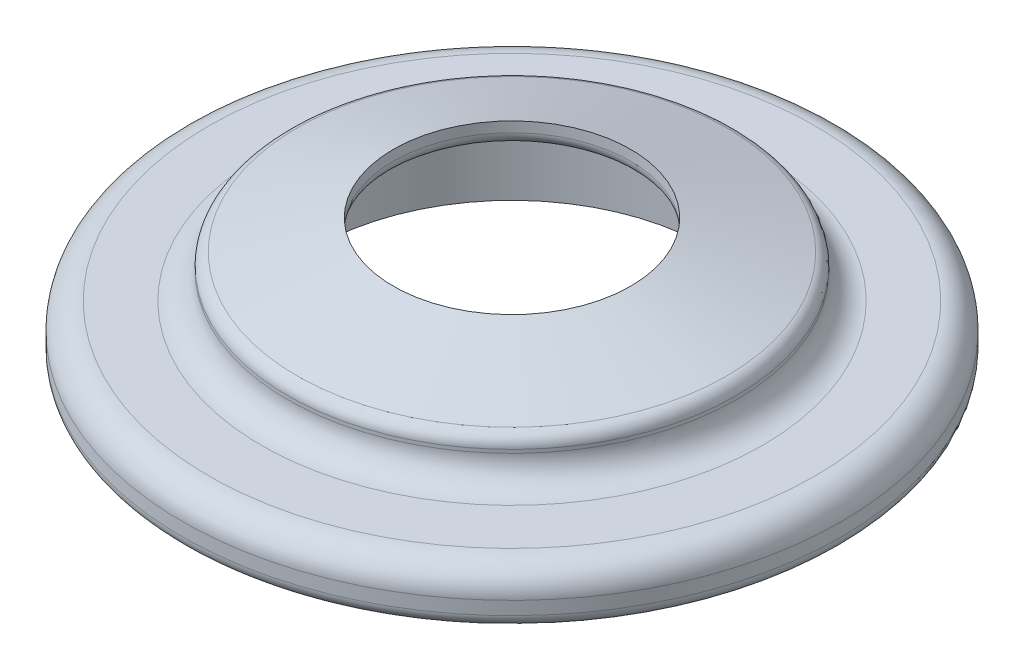
from build123d import *


with BuildPart() as part:
    # Sketch1 → Revolve1 (revolve)
    with BuildSketch(Plane.XY):
        with BuildLine():
            Line((0, 0), (-24, 0))
            ThreePointArc((-24, 0), (-24.707106781, 0.292893219), (-25, 1))
            Line((-25, 1), (-25, 2))
            ThreePointArc((-25, 2), (-24.414213562, 3.414213562), (-23, 4))
            Line((-23, 4), (-19, 4))
            ThreePointArc((-19, 4), (-17.585786438, 4.585786438), (-17, 6))
            Line((-17, 6), (-17, 6.261425345))
            ThreePointArc((-17, 6.261425345), (-16.804389784, 6.855527252), (-16.294085849, 7.217204354))
            Line((-16.294085849, 7.217204354), (-4.143718222, 10.955779009))
            ThreePointArc((-4.143718222, 10.955779009), (-3.998328357, 10.988882958), (-3.849632373, 11))
            Line((-3.849632373, 11), (0, 11))
            Line((0, 11), (0, 0))
        make_face()
    revolve(axis=Axis((0, 0, 0), (0, 1, 0)))

    # Sketch3 → Cut-Revolve2 (revolve, cut)
    with BuildSketch(Plane.XY):
        with BuildLine():
            Line((0, 11), (0, 0))
            Line((0, 0), (-15, 0))
            Line((-15, 0), (-15, 6.305273568))
            ThreePointArc((-15, 6.305273568), (-14.738894744, 6.979094433), (-14.091930885, 7.301038958))
            Line((-14.091930885, 7.301038958), (-9.908069115, 7.687300741))
            ThreePointArc((-9.908069115, 7.687300741), (-9.261105256, 8.009245267), (-9, 8.683066131))
            Line((-9, 8.683066131), (-9, 11))
            Line((-9, 11), (0, 11))
        make_face()
    revolve(axis=Axis((0, 11, 0), (0, -1, 0)), mode=Mode.SUBTRACT)


solid = part.part
